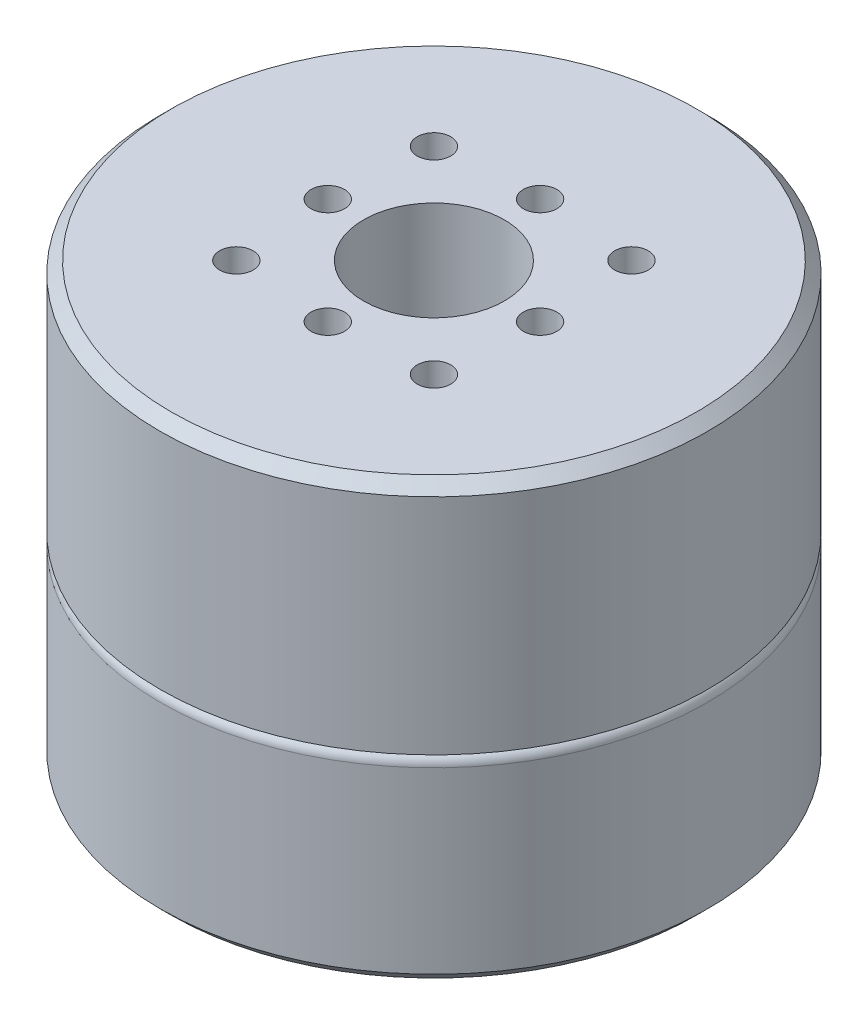
from build123d import *

# Parameters (mm, degrees)
SKETCH_1_R          = 24.5
EXTRUDE_1_DEPTH     = 18
FILLET_1_R          = 1
SKETCH_2_R          = 24.5
EXTRUDE_2_DEPTH     = 21
CHAMFER_1_SIZE      = 1
CHAMFER_2_SIZE      = 1
SKETCH_4_R          = 6.3
CUT_EXTRUDE_1_DEPTH = 10
SKETCH_5_R          = 1.5
CUT_EXTRUDE_2_DEPTH = 5
SKETCH_6_R          = 1.5
CUT_EXTRUDE_3_DEPTH = 5


with BuildPart() as part:
    # 草图1 → 凸台-拉伸1 (new body)
    with BuildSketch(Plane(origin=(0, 0, 0), x_dir=(1, 0, 0), z_dir=(0, 1, 0))):
        Circle(SKETCH_1_R)
    extrude(amount=EXTRUDE_1_DEPTH)

    # 圆角1
    fillet_1_edges = [part.edges().sort_by_distance(p)[0] for p in [
        (-24.5, 18, 0),
    ]]
    fillet(fillet_1_edges, radius=FILLET_1_R)

    # 草图2 → 凸台-拉伸2 (add)
    with BuildSketch(Plane(origin=(0, 18, 0), x_dir=(1, 0, 0), z_dir=(0, 1, 0))):
        Circle(SKETCH_2_R)
    extrude(amount=EXTRUDE_2_DEPTH)

    # 倒角1
    chamfer_1_edges = [part.edges().sort_by_distance(p)[0] for p in [
        (-24.5, 39, 0),
    ]]
    chamfer(chamfer_1_edges, length=CHAMFER_1_SIZE)

    # 倒角2
    chamfer_2_edges = [part.edges().sort_by_distance(p)[0] for p in [
        (-24.5, 0, 0),
    ]]
    chamfer(chamfer_2_edges, length=CHAMFER_2_SIZE)

    # 草图4 → 切除-拉伸1 (cut)
    with BuildSketch(Plane(origin=(0, 39, 0), x_dir=(1, 0, 0), z_dir=(0, 1, 0))):
        Circle(SKETCH_4_R)
    extrude(amount=-CUT_EXTRUDE_1_DEPTH, mode=Mode.SUBTRACT)

    # 草图5 → 切除-拉伸2 (cut)
    with BuildSketch(Plane(origin=(0, 39, 0), x_dir=(1, 0, 0), z_dir=(0, 1, 0))):
        with Locations((9.5, 0)):
            Circle(SKETCH_5_R)
        with Locations((0, -9.5)):
            Circle(SKETCH_5_R)
        with Locations((-9.5, 0)):
            Circle(SKETCH_5_R)
        with Locations((0, 9.5)):
            Circle(SKETCH_5_R)
        with Locations((8.838834765, 8.838834765)):
            Circle(SKETCH_5_R)
        with Locations((8.838834765, -8.838834765)):
            Circle(SKETCH_5_R)
        with Locations((-8.838834765, -8.838834765)):
            Circle(SKETCH_5_R)
        with Locations((-8.838834765, 8.838834765)):
            Circle(SKETCH_5_R)
    extrude(amount=-CUT_EXTRUDE_2_DEPTH, mode=Mode.SUBTRACT)

    # 草图6 → 切除-拉伸3 (cut)
    with BuildSketch(Plane.XZ):
        with Locations((15, 0)):
            Circle(SKETCH_6_R)
        with Locations((0, -15)):
            Circle(SKETCH_6_R)
        with Locations((-15, 0)):
            Circle(SKETCH_6_R)
        with Locations((0, 15)):
            Circle(SKETCH_6_R)
    extrude(amount=-CUT_EXTRUDE_3_DEPTH, mode=Mode.SUBTRACT)


solid = part.part
